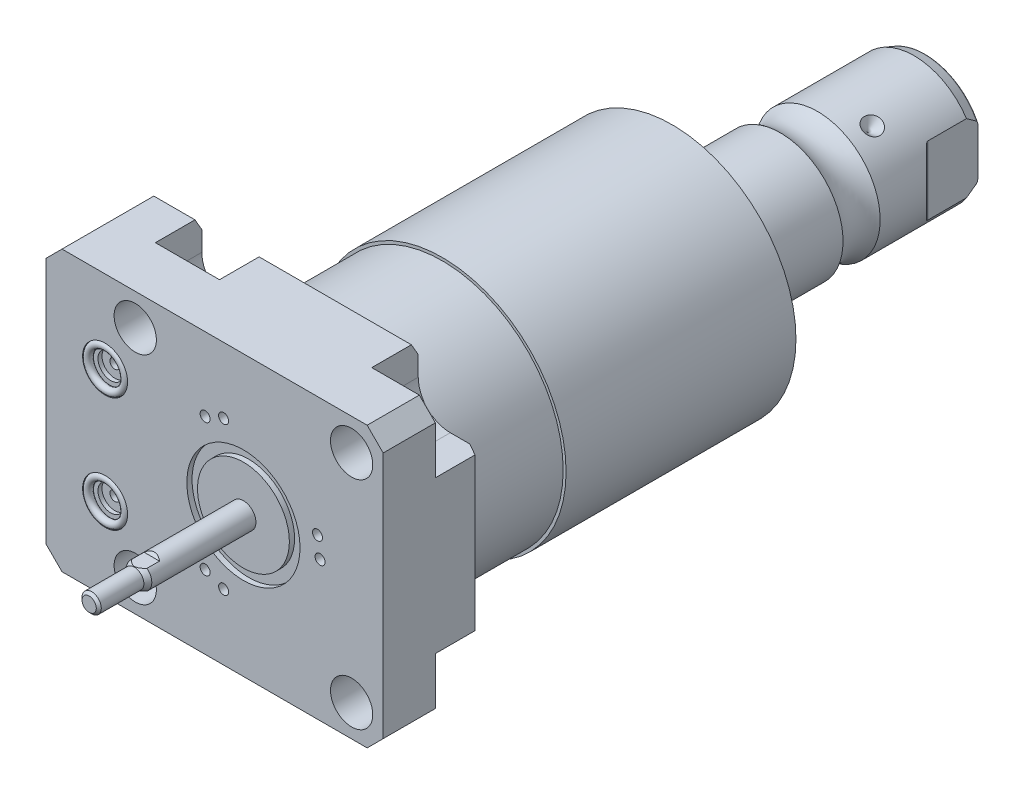
from build123d import *

# Parameters (mm, degrees)
SKETCH1_W               = 85.496
SKETCH1_H               = 70.866
EXTRUDE1_DEPTH          = 25.019
HOLE1_D                 = 10.719
CUT_EXTRUDE2_DEPTH      = 11.786
SKETCH6_R               = 5.7023
CUT_EXTRUDE3_DEPTH      = 1.4478
SKETCH7_R               = 3.2512
CUT_EXTRUDE4_DEPTH      = 1.016
SKETCH8_R               = 1.2446
CUT_EXTRUDE5_DEPTH      = 11.9888
SKETCH9_R               = 0.9271
CHAMFER1_SIZE           = 4.064
CHAMFER2_SIZE           = 3.0226
CHAMFER2_SIZE2          = 1.745098924
CIRPATTERN1_COUNT       = 3
FILLET2_R               = 0.635
CUT_EXTRUDE8_DEPTH      = 36.433
CUT_EXTRUDE8_DEPTH_BACK = 36.433
CUT_EXTRUDE9_DEPTH      = 3.81000762
SKETCH37_W              = 1.320802642
SKETCH37_H              = 2.70510541
SKETCH38_R              = 1.27000254
CUT_EXTRUDE10_DEPTH     = 7.62001524


with BuildPart() as part:
    # Sketch1 → Extrude1 (new body)
    with BuildSketch(Plane.XY):
        with Locations((-7.315, 0)):
            Rectangle(SKETCH1_W, SKETCH1_H)
    extrude(amount=EXTRUDE1_DEPTH)

    # Hole1 (through all)
    with Locations(Plane(origin=(0, 0, 0), x_dir=(-1, 0, 0), z_dir=(0, 0, -1))):
        with Locations((-27.432, -27.432), (-27.432, 27.432), (27.432, 27.432), (27.432, -27.432)):
            Hole(HOLE1_D / 2)

    # Sketch3 → Cut-Extrude2 (cut)
    with BuildSketch(Plane(origin=(0, 0, 0), x_dir=(-1, 0, 0), z_dir=(0, 0, -1))):
        with BuildLine():
            Line((-27.432, -19.304), (-35.433, -19.304))
            Line((-35.433, -19.304), (-35.433, -35.433))
            Line((-35.433, -35.433), (-19.304, -35.433))
            Line((-19.304, -35.433), (-19.304, -27.432))
            ThreePointArc((-19.304, -27.432), (-21.684636083, -21.684636083), (-27.432, -19.304))
        make_face()
        with BuildLine():
            Line((-35.433, 19.304), (-35.433, 35.433))
            Line((-35.433, 35.433), (-19.304, 35.433))
            Line((-19.304, 35.433), (-19.304, 27.432))
            ThreePointArc((-19.304, 27.432), (-21.684636083, 21.684636083), (-27.432, 19.304))
            Line((-27.432, 19.304), (-35.433, 19.304))
        make_face()
        with BuildLine():
            Line((19.304, 35.433), (19.304, 27.432))
            ThreePointArc((19.304, 27.432), (27.432, 19.304), (35.56, 27.432))
            Line((35.56, 27.432), (35.56, 35.433))
            Line((35.56, 35.433), (19.304, 35.433))
        make_face()
        with BuildLine():
            Line((35.56, -35.433), (19.304, -35.433))
            Line((19.304, -35.433), (19.304, -27.432))
            ThreePointArc((19.304, -27.432), (27.432, -19.304), (35.56, -27.432))
            Line((35.56, -27.432), (35.56, -35.433))
        make_face()
    extrude(amount=-CUT_EXTRUDE2_DEPTH, mode=Mode.SUBTRACT)

    # Sketch23 → Cut-Revolve5 (revolve, cut)
    with BuildSketch(Plane.XY.offset(12.522), mode=Mode.PRIVATE) as cut_revolve5_sk:
        Polygon((-50.063, -23.749), (-49.809, -23.749), (-49.809, -19.6596), (-49.0978, -18.9484), (-35.6358, -18.9484), (-35.6358, -13.0048), (-50.063, -13.0048), align=None)
    cut_revolve5 = revolve(cut_revolve5_sk.sketch.rotate(Axis((-11.939660979, -13.0048, 12.522), (-1, 0, 0)), 180), axis=Axis((-11.939660979, -13.0048, 12.522), (-1, 0, 0)), mode=Mode.SUBTRACT)  # turned: the seam where the file's is

    # Mirror1: Cut-Revolve5 across plane
    add(cut_revolve5.mirror(Plane.ZX), mode=Mode.SUBTRACT)

    # Sketch6 → Cut-Extrude3 (cut)
    with BuildSketch(Plane.XY.offset(25.019)):
        with Locations((-35.077, -14.529)):
            Circle(SKETCH6_R)
        with Locations((-35.077, 14.529)):
            Circle(SKETCH6_R)
    extrude(amount=-CUT_EXTRUDE3_DEPTH, mode=Mode.SUBTRACT)

    # Sketch7 → Cut-Extrude4 (cut)
    with BuildSketch(Plane.XY.offset(23.5712)):
        with Locations((-35.077, 14.529)):
            Circle(SKETCH7_R)
        with Locations((-35.077, -14.529)):
            Circle(SKETCH7_R)
    extrude(amount=-CUT_EXTRUDE4_DEPTH, mode=Mode.SUBTRACT)

    # Sketch8 → Cut-Extrude5 (cut)
    with BuildSketch(Plane.XY.offset(22.5552)):
        with Locations((-35.077, 14.529)):
            Circle(SKETCH8_R)
        with Locations((-35.077, -14.529)):
            Circle(SKETCH8_R)
    extrude(amount=-CUT_EXTRUDE5_DEPTH, mode=Mode.SUBTRACT)

    # Chamfer1
    chamfer1_edges = [part.edges().sort_by_distance(p)[0] for p in [
        (-50.063, 35.433, 12.5095),
        (35.433, 35.433, 18.4025),
        (35.433, -35.433, 18.4025),
        (-50.063, -35.433, 12.5095),
    ]]
    chamfer(chamfer1_edges, length=CHAMFER1_SIZE)

    # Chamfer2
    chamfer2_edges = [part.edges().sort_by_distance(p)[0] for p in [
        (-40.7795, -35.433, 0),
        (35.433, 0, 0),
        (0, 35.433, 0),
        (-40.7795, 35.433, 0),
        (0, -35.433, 0),
    ]]
    chamfer2_side = [part.faces().sort_by_distance(p)[0] for p in [
        (-8.721219411, 0, 0),
    ]]
    chamfer(chamfer2_edges, length=CHAMFER2_SIZE, length2=CHAMFER2_SIZE2, reference=chamfer2_side[0])

    # Sketch24 → Revolve4 (revolve)
    with BuildSketch(Plane(origin=(0, 0, 0), x_dir=(0, 0, -1), z_dir=(1, 0, 0)), mode=Mode.PRIVATE) as revolve4_sk:
        Polygon((0, 0), (0, 30.658), (25.4, 30.658), (25.4, 31.3945), (83.687301194, 31.3945), (86.995, 19.05), (86.995, 0), align=None)
    revolve(revolve4_sk.sketch.rotate(Axis((0, 0, 0), (0, 0, -1)), 90), axis=Axis((0, 0, 0), (0, 0, -1)))  # turned: the seam where the file's is

    # Sketch17 → Revolve3 (revolve)
    with BuildSketch(Plane(origin=(0, 0, 0), x_dir=(0, 0, -1), z_dir=(1, 0, 0)), mode=Mode.PRIVATE) as revolve3_sk:
        with BuildLine():
            Line((86.995, 0), (86.995, -15.875))
            Line((86.995, -15.875), (111.141705156, -15.875))
            ThreePointArc((111.141705156, -15.875), (115.849, -14.3255), (120.556294844, -15.875))
            Line((120.556294844, -15.875), (145.03399416, -15.875))
            Line((145.03399416, -15.875), (147.955, -14.81184082))
            Line((147.955, -14.81184082), (147.955, 0))
            Line((147.955, 0), (86.995, 0))
        make_face()
    revolve(revolve3_sk.sketch.rotate(Axis((0, 0, -130.8989), (0, 0, 1)), 270), axis=Axis((0, 0, -130.8989), (0, 0, 1)))  # turned: the seam where the file's is

    # Sketch30 → Cut-Revolve6 (revolve, cut)
    with BuildSketch(Plane(origin=(0, 0, 0), x_dir=(1, 0, 0), z_dir=(0, 1, 0)), mode=Mode.PRIVATE) as cut_revolve6_sk:
        Polygon((-15.875, 128.93), (-13.462, 126.517), (-15.875, 126.517), align=None)
    cut_revolve6 = revolve(cut_revolve6_sk.sketch.rotate(Axis((-27.819320819, 0, -126.517), (1, 0, 0)), 180), axis=Axis((-27.819320819, 0, -126.517), (1, 0, 0)), mode=Mode.SUBTRACT)  # turned: the seam where the file's is

    # CirPattern1: Cut-Revolve6 ×3 about axis
    cirpattern1_axis = Axis((0, 0, -130.8989), (0, 0, -1))
    for i in range(1, CIRPATTERN1_COUNT):
        add(cut_revolve6.rotate(cirpattern1_axis, i * 360 / CIRPATTERN1_COUNT), mode=Mode.SUBTRACT)

    # Fillet2
    fillet2_edges = [part.edges().sort_by_distance(p)[0] for p in [
        (14.81184082, 0, -147.955),
    ]]
    fillet(fillet2_edges, radius=FILLET2_R)

    # Sketch32 → Cut-Extrude8 (cut, two sides)
    with BuildSketch(Plane(origin=(0, 0, 0), x_dir=(1, 0, 0), z_dir=(0, 1, 0))) as cut_extrude8_sk:
        with BuildLine():
            Line((-13.284, 147.955), (-13.284, 135.255))
            ThreePointArc((-13.284, 135.255), (-13.342003912, 134.963394643), (-13.507185078, 134.716183558))
            Line((-13.507185078, 134.716183558), (-15.875, 132.348368636))
            Line((-15.875, 132.348368636), (-15.875, 147.955))
            Line((-15.875, 147.955), (-13.284, 147.955))
        make_face()
        with BuildLine():
            Line((15.875, 147.955), (13.284, 147.955))
            Line((13.284, 147.955), (13.284, 135.255))
            ThreePointArc((13.284, 135.255), (13.342003912, 134.963394643), (13.507185078, 134.716183558))
            Line((13.507185078, 134.716183558), (15.875, 132.348368636))
            Line((15.875, 132.348368636), (15.875, 147.955))
        make_face()
    extrude(amount=CUT_EXTRUDE8_DEPTH, mode=Mode.SUBTRACT)
    extrude(cut_extrude8_sk.sketch, amount=-CUT_EXTRUDE8_DEPTH_BACK, mode=Mode.SUBTRACT)

    # Sketch33 → Hole2 (revolve, cut)
    with BuildSketch(Plane(origin=(0, 0, -147.955), x_dir=(0, 1, 0), z_dir=(1, 0, 0))):
        Polygon((0, 0), (0, 29.566487704), (6.9342, 25.4), (6.9342, 0), align=None)
    revolve(axis=Axis((0, 0, -152.199199587), (0, 0, 1)), mode=Mode.SUBTRACT)

    # Sketch35 → Revolve5 (revolve)
    with BuildSketch(Plane(origin=(0, 0, 0), x_dir=(0, 0, -1), z_dir=(1, 0, 0)), mode=Mode.PRIVATE) as revolve5_sk:
        Polygon((-25.019, 0), (-25.019, -3.17500635), (-51.429570144, -3.17500635), (-52.705401321, -2.438404877), (-63.500422911, -2.438404877), (-64.135424181, -1.803403607), (-64.135424181, 0), align=None)
    revolve(revolve5_sk.sketch.rotate(Axis((0, 0, 1000), (0, 0, -1)), 270), axis=Axis((0, 0, 1000), (0, 0, -1)))  # turned: the seam where the file's is

    # Sketch36 → Cut-Extrude9 (cut, symmetric)
    with BuildSketch(Plane(origin=(0, 0, 0), x_dir=(0, 0, -1), z_dir=(1, 0, 0))):
        Polygon((-47.587291085, -3.17500635), (-48.260392431, -2.501905004), (-64.135424181, -2.501905004), (-64.135424181, -3.17500635), align=None)
        Polygon((-47.587291085, 3.17500635), (-48.260392431, 2.501905004), (-64.135424181, 2.501905004), (-64.135424181, 3.17500635), align=None)
    extrude(amount=CUT_EXTRUDE9_DEPTH, both=True, mode=Mode.SUBTRACT)

    # Sketch37 → Cut-Revolve7 (revolve, cut)
    with BuildSketch(Plane(origin=(0, 0, 0), x_dir=(0, 0, -1), z_dir=(1, 0, 0)), mode=Mode.PRIVATE) as cut_revolve7_sk:
        with Locations((-24.358598679, -12.998475997)):
            Rectangle(SKETCH37_W, SKETCH37_H)
    revolve(cut_revolve7_sk.sketch.rotate(Axis((0, 0, 1000), (0, 0, -1)), 270), axis=Axis((0, 0, 1000), (0, 0, -1)), mode=Mode.SUBTRACT)  # turned: the seam where the file's is

    # Sketch38 → Cut-Extrude10 (cut)
    with BuildSketch(Plane.XY.offset(25.019)):
        with Locations((19.431038862, 0)):
            Circle(SKETCH38_R)
        with Locations((18.768942269, 5.029122924)):
            Circle(SKETCH38_R)
        with Locations(Location((-5.029122924, 18.768942269, 0), (0, 0, 180))):  # turned: the seam where the file's is
            Circle(SKETCH38_R)
        with Locations(Location((-9.715519431, 16.827773276, 0), (0, 0, 180))):  # turned: the seam where the file's is
            Circle(SKETCH38_R)
        with Locations((-5.029122924, -18.768942269)):
            Circle(SKETCH38_R)
        with Locations((-9.715519431, -16.827773276)):
            Circle(SKETCH38_R)
    extrude(amount=-CUT_EXTRUDE10_DEPTH, mode=Mode.SUBTRACT)


with BuildPart() as body_2:
    # Sketch9 → Revolve1 (revolve)
    with BuildSketch(Plane(origin=(-41.656, 14.5288, 23.5712), x_dir=(1, 0, 0), z_dir=(0, 1, 0))):
        with Locations((11.3542, -0.9271)):
            Circle(SKETCH9_R)
    revolve(axis=Axis((-35.077, 14.5288, 25.51811), (0, 0, -1)))


with BuildPart() as body_3:
    # Mirror2: mirrored copy
    add(body_2.part.mirror(Plane.ZX))


solid = Compound([part.part, body_2.part, body_3.part])
